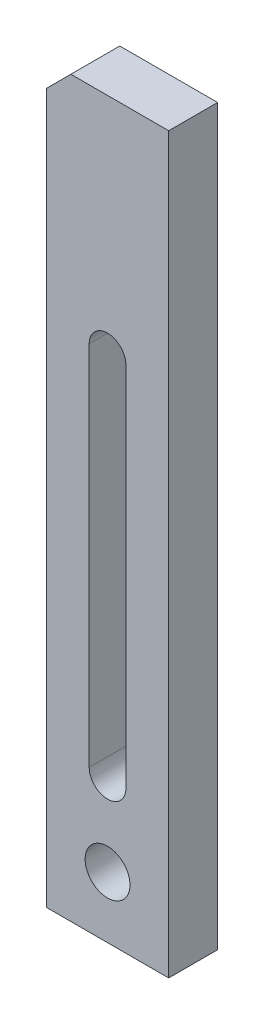
from build123d import *

# Parameters (mm, degrees)
SKETCH_1_W          = 30
SKETCH_1_H          = 180
EXTRUDE_1_DEPTH     = 12
SKETCH_2_R          = 5.5
CUT_EXTRUDE_1_DEPTH = 12
CHAMFER_1_SIZE      = 6


with BuildPart() as part:
    # 草图1 → 凸台-拉伸1 (new body)
    with BuildSketch(Plane.XY):
        Rectangle(SKETCH_1_W, SKETCH_1_H)
    extrude(amount=EXTRUDE_1_DEPTH)

    # 草图2 → 切除-拉伸1 (cut)
    with BuildSketch(Plane.XY.offset(12)):
        with Locations((0, -75)):
            Circle(SKETCH_2_R)
        with BuildLine():
            Line((4.5, 35), (4.5, -55))
            ThreePointArc((4.5, -55), (0, -59.5), (-4.5, -55))
            Line((-4.5, -55), (-4.5, 35))
            ThreePointArc((-4.5, 35), (0, 39.5), (4.5, 35))
        make_face()
    extrude(amount=-CUT_EXTRUDE_1_DEPTH, mode=Mode.SUBTRACT)

    # 倒角1
    chamfer_1_edges = [part.edges().sort_by_distance(p)[0] for p in [
        (-15, 90, 6),
    ]]
    chamfer(chamfer_1_edges, length=CHAMFER_1_SIZE)


solid = part.part
